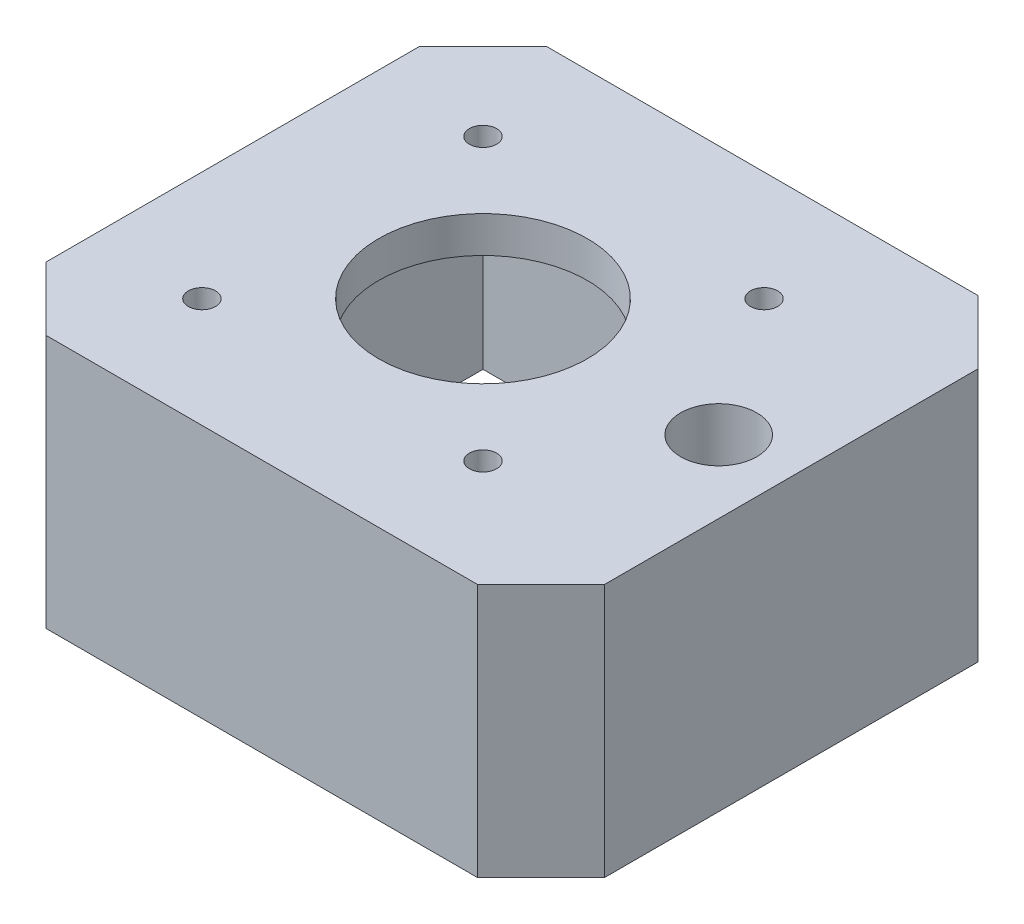
from build123d import *

# Parameters (mm, degrees)
SKETCH1_W           = 55
SKETCH1_H           = 42
SKETCH1_R           = 4.2
SKETCH1_R_2         = 11.5
SKETCH1_R_3         = 1.5
BOSS_EXTRUDE1_DEPTH = 4
SKETCH2_R           = 4.2
BOSS_EXTRUDE2_DEPTH = 20
SKETCH3_W           = 12.75
SKETCH3_H           = 20
BOSS_EXTRUDE3_DEPTH = 4
SKETCH4_W           = 55.2
SKETCH4_H           = 55.2
SKETCH4_W_2         = 42.5
SKETCH4_H_2         = 42.5
BOSS_EXTRUDE4_DEPTH = 24
SKETCH5_R           = 4.2
CUT_EXTRUDE1_DEPTH  = 20
SKETCH6_W           = 6.6
SKETCH6_H           = 4
BOSS_EXTRUDE6_DEPTH = 48.6
SKETCH7_W           = 6.6
SKETCH7_H           = 4
BOSS_EXTRUDE7_DEPTH = 55.2
BOSS_EXTRUDE8_DEPTH = 6.4
CUT_EXTRUDE2_DEPTH  = 28


with BuildPart() as part:
    # Sketch1 → Boss-Extrude1 (new body)
    with BuildSketch(Plane(origin=(0, 0, 0), x_dir=(1, 0, 0), z_dir=(0, 1, 0))):
        with Locations((27.5, 21)):
            Rectangle(SKETCH1_W, SKETCH1_H)
        with Locations((47, 21)):
            Circle(SKETCH1_R, mode=Mode.SUBTRACT)
        with Locations((21, 21)):
            Circle(SKETCH1_R_2, mode=Mode.SUBTRACT)
        with Locations((5.5, 36.5)):
            Circle(SKETCH1_R_3, mode=Mode.SUBTRACT)
        with Locations((36.5, 36.5)):
            Circle(SKETCH1_R_3, mode=Mode.SUBTRACT)
        with Locations((5.5, 5.5)):
            Circle(SKETCH1_R_3, mode=Mode.SUBTRACT)
        with Locations((36.5, 5.5)):
            Circle(SKETCH1_R_3, mode=Mode.SUBTRACT)
    extrude(amount=BOSS_EXTRUDE1_DEPTH)

    # Sketch2 → Boss-Extrude2 (add)
    with BuildSketch(Plane.XZ):
        with BuildLine():
            ThreePointArc((53.6, -21), (49.47082982, -14.879950981), (42.25, -16.417697086))
            Line((42.25, -16.417697086), (42.25, -25.582302914))
            ThreePointArc((42.25, -25.582302914), (49.47082982, -27.120049019), (53.6, -21))
        make_face()
        with Locations((47, -21)):
            Circle(SKETCH2_R, mode=Mode.SUBTRACT)
        with BuildLine():
            Line((55, -11), (42.25, -11))
            Line((42.25, -11), (42.25, -16.417697086))
            ThreePointArc((42.25, -16.417697086), (49.47082982, -14.879950981), (53.6, -21))
            ThreePointArc((53.6, -21), (49.47082982, -27.120049019), (42.25, -25.582302914))
            Line((42.25, -25.582302914), (42.25, -31))
            Line((42.25, -31), (55, -31))
            Line((55, -31), (55, -11))
        make_face()
    extrude(amount=BOSS_EXTRUDE2_DEPTH)

    # Sketch3 → Boss-Extrude3 (add)
    with BuildSketch(Plane.XZ.offset(20)):
        with Locations((48.625, -21)):
            Rectangle(SKETCH3_W, SKETCH3_H)
    extrude(amount=BOSS_EXTRUDE3_DEPTH)

    # Sketch4 → Boss-Extrude4 (add)
    with BuildSketch(Plane.XZ):
        with Locations((21, -21)):
            Rectangle(SKETCH4_W, SKETCH4_H)
        with Locations((21, -21)):
            Rectangle(SKETCH4_W_2, SKETCH4_H_2, mode=Mode.SUBTRACT)
    extrude(amount=BOSS_EXTRUDE4_DEPTH)

    # Sketch5 → Cut-Extrude1 (cut)
    with BuildSketch(Plane(origin=(0, 0, 0), x_dir=(1, 0, 0), z_dir=(0, 1, 0))):
        with Locations((47, 21)):
            Circle(SKETCH5_R)
    extrude(amount=-CUT_EXTRUDE1_DEPTH, mode=Mode.SUBTRACT)

    # Sketch6 → Boss-Extrude6 (add)
    with BuildSketch(Plane(origin=(48.6, 0, 0), x_dir=(0, 0, -1), z_dir=(1, 0, 0))):
        with Locations((45.3, 2)):
            Rectangle(SKETCH6_W, SKETCH6_H)
        with Locations((-3.3, 2)):
            Rectangle(SKETCH6_W, SKETCH6_H)
    extrude(amount=-BOSS_EXTRUDE6_DEPTH)

    # Sketch7 → Boss-Extrude7 (add)
    with BuildSketch(Plane(origin=(0, 0, -48.6), x_dir=(-1, 0, 0), z_dir=(0, 0, -1))):
        with Locations((3.3, 2)):
            Rectangle(SKETCH7_W, SKETCH7_H)
    extrude(amount=-BOSS_EXTRUDE7_DEPTH)

    # Sketch8 → Boss-Extrude8 (add)
    with BuildSketch(Plane(origin=(48.6, 0, 0), x_dir=(0, 0, -1), z_dir=(1, 0, 0))):
        Polygon((42, 0), (31, 0), (31, -24), (48.6, -24), (48.6, 4), (42, 4), align=None)
        Polygon((11, -24), (11, 0), (0, 0), (0, 4), (-6.6, 4), (-6.6, -24), align=None)
    extrude(amount=BOSS_EXTRUDE8_DEPTH)

    # Sketch9 → Cut-Extrude2 (cut)
    with BuildSketch(Plane(origin=(0, 4, 0), x_dir=(1, 0, 0), z_dir=(0, 1, 0))):
        Polygon((55, 0.4), (48, -6.6), (55, -6.6), align=None)
        Polygon((55, 41.6), (48, 48.6), (55, 48.6), align=None)
        Polygon((0.4, 48.6), (-6.6, 48.6), (-6.6, 41.6), align=None)
        Polygon((0.4, -6.6), (-6.6, 0.4), (-6.6, -6.6), align=None)
    extrude(amount=-CUT_EXTRUDE2_DEPTH, mode=Mode.SUBTRACT)


solid = part.part
